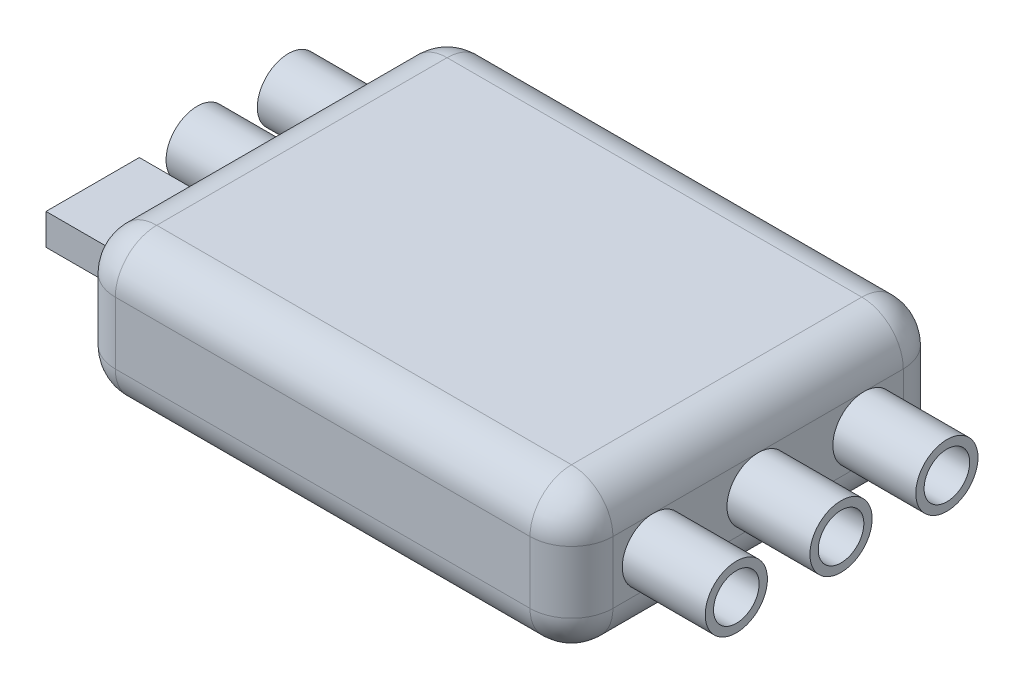
from build123d import *

# Parameters (mm, degrees)
BOSS_EXTRUDE1_DEPTH = 7
FILLET1_R           = 2
SKETCH3_R           = 1.5
SKETCH3_R_2         = 1.1
BOSS_EXTRUDE2_DEPTH = 4
SKETCH4_R           = 1.5
SKETCH4_R_2         = 1.1
SKETCH4_W           = 4.5
SKETCH4_H           = 1.5
BOSS_EXTRUDE3_DEPTH = 4


with BuildPart() as part:
    # Sketch2 → Boss-Extrude1 (new body)
    with BuildSketch(Plane(origin=(0, 0, 0), x_dir=(1, 0, 0), z_dir=(0, 1, 0))):
        with BuildLine():
            Line((-10, 9), (10, 9))
            ThreePointArc((10, 9), (11.414213562, 8.414213562), (12, 7))
            Line((12, 7), (12, -7))
            ThreePointArc((12, -7), (11.414213562, -8.414213562), (10, -9))
            Line((10, -9), (-10, -9))
            ThreePointArc((-10, -9), (-11.414213562, -8.414213562), (-12, -7))
            Line((-12, -7), (-12, 7))
            ThreePointArc((-12, 7), (-11.414213562, 8.414213562), (-10, 9))
        make_face()
    extrude(amount=BOSS_EXTRUDE1_DEPTH)

    # Fillet1
    fillet1_edges = [part.edges().sort_by_distance(p)[0] for p in [
        (-12, 0, 0),
        (-11.414213562, 0, -8.414213562),
        (0, 0, -9),
        (11.414213562, 0, -8.414213562),
        (-11.414213562, 7, -8.414213562),
        (-12, 7, 0),
        (-11.414213562, 7, 8.414213562),
        (0, 7, 9),
        (11.414213562, 7, 8.414213562),
        (12, 7, 0),
        (11.414213562, 7, -8.414213562),
        (12, 0, 0),
        (0, 7, -9),
        (11.414213562, 0, 8.414213562),
        (0, 0, 9),
        (-11.414213562, 0, 8.414213562),
    ]]
    fillet(fillet1_edges, radius=FILLET1_R)

    # Sketch3 → Boss-Extrude2 (add)
    with BuildSketch(Plane(origin=(12, 0, 0), x_dir=(0, 0, -1), z_dir=(1, 0, 0))):
        with Locations((-5.049719727, 3.5)):
            Circle(SKETCH3_R)
        with Locations((-5.049719727, 3.5)):
            Circle(SKETCH3_R_2, mode=Mode.SUBTRACT)
        with Locations((0, 3.5)):
            Circle(SKETCH3_R)
        with Locations((0, 3.5)):
            Circle(SKETCH3_R_2, mode=Mode.SUBTRACT)
        with Locations((5.10473286, 3.5)):
            Circle(SKETCH3_R)
        with Locations((5.10473286, 3.5)):
            Circle(SKETCH3_R_2, mode=Mode.SUBTRACT)
    extrude(amount=BOSS_EXTRUDE2_DEPTH)

    # Sketch4 → Boss-Extrude3 (add)
    with BuildSketch(Plane.ZY.offset(12)):
        with Locations((-5.349391093, 3.5)):
            Circle(SKETCH4_R)
        with Locations((-5.349391093, 3.5)):
            Circle(SKETCH4_R_2, mode=Mode.SUBTRACT)
        with Locations((-0.949391093, 3.5)):
            Circle(SKETCH4_R)
        with Locations((-0.949391093, 3.5)):
            Circle(SKETCH4_R_2, mode=Mode.SUBTRACT)
        with Locations((4.090650699, 3.5)):
            Rectangle(SKETCH4_W, SKETCH4_H)
    extrude(amount=BOSS_EXTRUDE3_DEPTH)


solid = part.part
